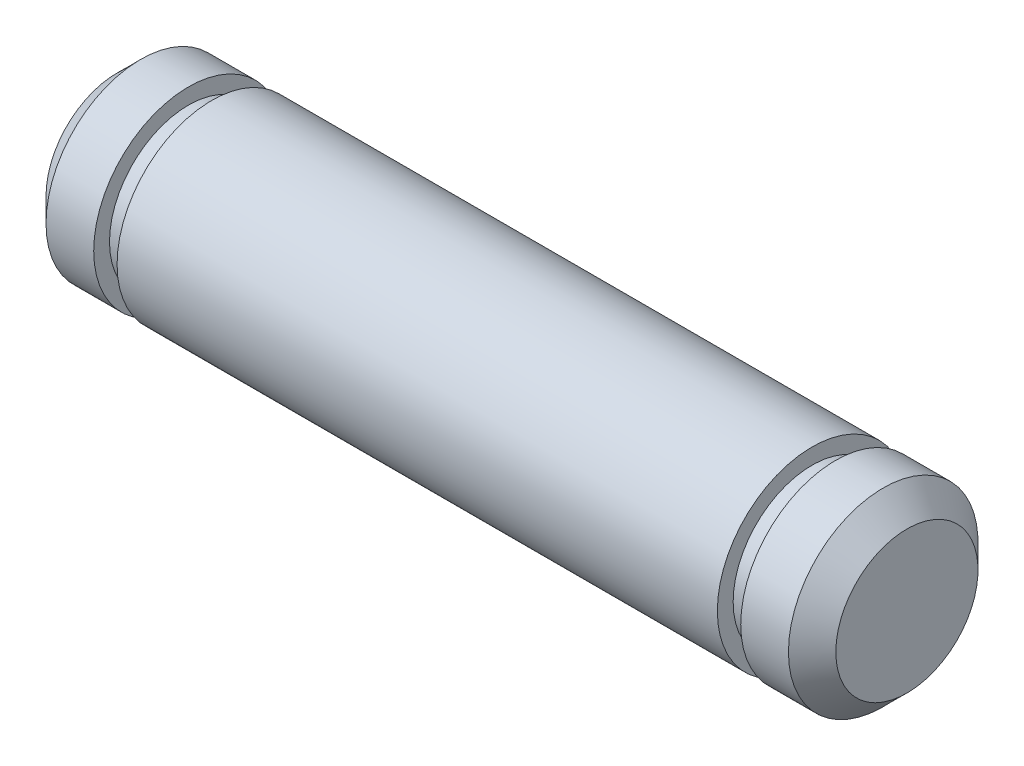
from build123d import *

# Parameters (mm, degrees)
SKETCH1_W = 25
SKETCH1_H = 3
SKETCH4_W = 0.74
SKETCH4_H = 0.5
SKETCH5_W = 0.74
SKETCH5_H = 0.5


with BuildPart() as part:
    # Sketch1 → Revolve1 (revolve)
    with BuildSketch(Plane.XY):
        with Locations((0, 1.5)):
            Rectangle(SKETCH1_W, SKETCH1_H)
    revolve(axis=Axis((12.5, 0, 0), (-1, 0, 0)))

    # Sketch2 → Cut-Revolve1 (revolve, cut)
    with BuildSketch(Plane.XY):
        Polygon((11.75, 3), (12.5, 2.25), (12.5, 3), align=None)
    revolve(axis=Axis((12.5, 0, 0), (-1, 0, 0)), mode=Mode.SUBTRACT)

    # Sketch3 → Cut-Revolve2 (revolve, cut)
    with BuildSketch(Plane.XY):
        Polygon((-12.5, 2.25), (-11.75, 3), (-12.5, 3), align=None)
    revolve(axis=Axis((12.5, 0, 0), (-1, 0, 0)), mode=Mode.SUBTRACT)

    # Sketch4 → Cut-Revolve3 (revolve, cut)
    with BuildSketch(Plane.XY):
        with Locations((9.87, 2.75)):
            Rectangle(SKETCH4_W, SKETCH4_H)
    revolve(axis=Axis((12.5, 0, 0), (-1, 0, 0)), mode=Mode.SUBTRACT)

    # Sketch5 → Cut-Revolve4 (revolve, cut)
    with BuildSketch(Plane.XY):
        with Locations((-9.87, 2.75)):
            Rectangle(SKETCH5_W, SKETCH5_H)
    revolve(axis=Axis((12.5, 0, 0), (-1, 0, 0)), mode=Mode.SUBTRACT)


solid = part.part
